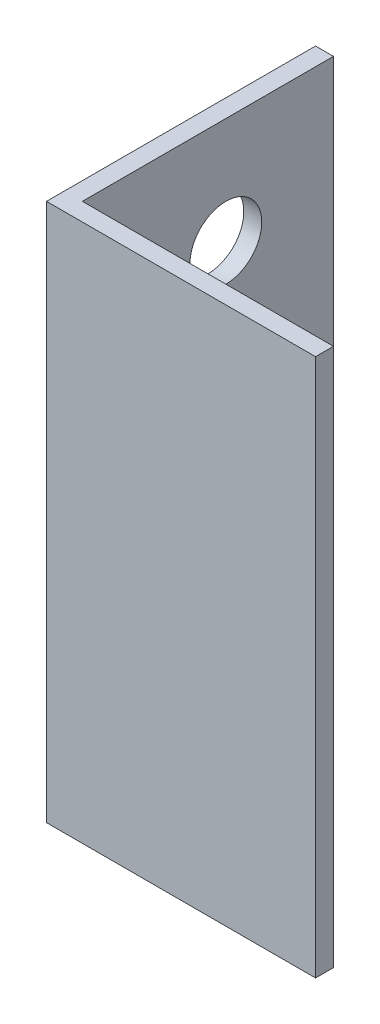
from build123d import *

# Parameters (mm, degrees)
EXTRUDE_1_DEPTH     = 150
SKETCH_2_R          = 10
CUT_EXTRUDE_1_DEPTH = 76


with BuildPart() as part:
    # Эскиз1 → Вытянуть-Тонкостенный1 (new body)
    with BuildSketch(Plane(origin=(0, 0, 0), x_dir=(1, 0, 0), z_dir=(0, 1, 0))):
        Polygon((0, 75), (0, 0), (75, 0), (75, 5), (5, 5), (5, 75), align=None)
    extrude(amount=EXTRUDE_1_DEPTH)

    # Эскиз2 → Вырез-Вытянуть1 (cut, through all)
    with BuildSketch(Plane.ZY):
        with Locations((-45, 120)):
            Circle(SKETCH_2_R)
    extrude(amount=-CUT_EXTRUDE_1_DEPTH, mode=Mode.SUBTRACT)


solid = part.part
